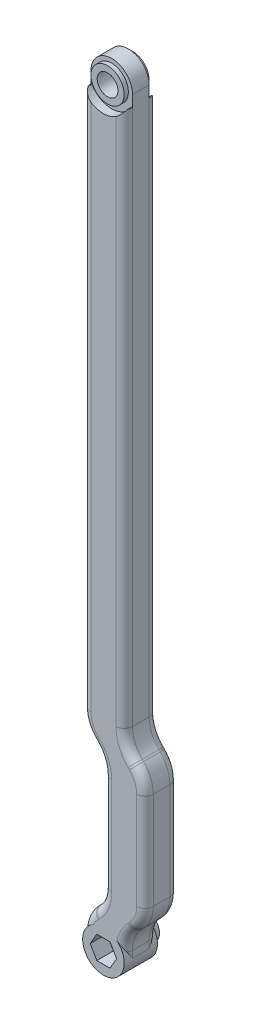
from build123d import *

# Parameters (mm, degrees)
EXTRUDE_1_DEPTH     = 8
FILLET_1_R          = 8
CUT_EXTRUDE_1_DEPTH = 1
SKETCH_3_R          = 2.5
EXTRUDE_2_DEPTH     = 4
SKETCH_4_R          = 4
CUT_EXTRUDE_3_DEPTH = 1
CUT_EXTRUDE_4_REACH = 13
SKETCH_5_R          = 2.5
CUT_EXTRUDE_START   = -7
SKETCH_4_2_R        = 4
CUT_EXTRUDE_5_DEPTH = 2
SKETCH_7_R          = 4
CUT_EXTRUDE_6_DEPTH = 1
FILLET_2_R          = 2
SKETCH_9_R          = 5
EXTRUDE_3_DEPTH     = 8
SKETCH_11_R         = 3
EXTRUDE_4_DEPTH     = 2.5
FILLET_3_R          = 1
SKETCH_12_R         = 1.6
CUT_EXTRUDE_8_DEPTH = 12
CUT_EXTRUDE_9_DEPTH = 4


with BuildPart() as part:
    # 草图1 → 凸台-拉伸1 (new body)
    with BuildSketch(Plane.XY):
        with BuildLine():
            Line((-5, -175), (-5, -180))
            ThreePointArc((-5, -180), (0, -185), (5, -180))
            Line((5, -180), (5, -175))
            Line((5, -175), (10, -170))
            Line((10, -170), (10, -140))
            Line((10, -140), (5, -135))
            Line((5, -135), (5, 0))
            ThreePointArc((5, 0), (0, 5), (-5, 0))
            Line((-5, 0), (-5, -135))
            Line((-5, -135), (0, -140))
            Line((0, -140), (0, -170))
            Line((0, -170), (-5, -175))
        make_face()
    extrude(amount=EXTRUDE_1_DEPTH)

    # 圆角1
    fillet_1_edges = [part.edges().sort_by_distance(p)[0] for p in [
        (5, -175, 4),
        (-5, -175, 4),
        (0, -170, 4),
        (0, -140, 4),
        (-5, -135, 4),
        (5, -135, 4),
        (10, -140, 4),
        (10, -170, 4),
    ]]
    fillet(fillet_1_edges, radius=FILLET_1_R)

    # 草图2 → 切除-拉伸1 (cut)
    with BuildSketch(Plane(origin=(0, 0, 0), x_dir=(-1, 0, 0), z_dir=(0, 0, -1))):
        with BuildLine():
            Line((5, 0), (5, -2.75))
            Line((5, -2.75), (4.763139721, -2.75))
            ThreePointArc((4.763139721, -2.75), (0, -5.5), (-4.763139721, -2.75))
            Line((-4.763139721, -2.75), (-5, -2.75))
            Line((-5, -2.75), (-5, 0))
            ThreePointArc((-5, 0), (0, 5), (5, 0))
        make_face()
    extrude(amount=-CUT_EXTRUDE_1_DEPTH, mode=Mode.SUBTRACT)

    # 草图3 → 凸台-拉伸2 (add)
    with BuildSketch(Plane(origin=(0, 0, 1), x_dir=(-1, 0, 0), z_dir=(0, 0, -1))):
        Circle(SKETCH_3_R)
    extrude(amount=EXTRUDE_2_DEPTH)

    # 草图4 → 切除-拉伸3 (cut)
    with BuildSketch(Plane(origin=(0, 0, 1), x_dir=(-1, 0, 0), z_dir=(0, 0, -1))):
        with BuildLine():
            Line((-5, 0), (-5, -2.75))
            Line((-5, -2.75), (-4.763139721, -2.75))
            ThreePointArc((-4.763139721, -2.75), (0, -5.5), (4.763139721, -2.75))
            Line((4.763139721, -2.75), (5, -2.75))
            Line((5, -2.75), (5, 0))
            ThreePointArc((5, 0), (0, 5), (-5, 0))
        make_face()
        Circle(SKETCH_4_R, mode=Mode.SUBTRACT)
    extrude(amount=-CUT_EXTRUDE_3_DEPTH, mode=Mode.SUBTRACT)

    # 草图5 → 切除-拉伸4 (cut, up to next)
    with BuildSketch(Plane.XY.offset(8), mode=Mode.PRIVATE) as cut_extrude_4_sk1:
        Circle(SKETCH_5_R)
    cut_extrude_4_tool1 = extrude(cut_extrude_4_sk1.sketch, amount=-CUT_EXTRUDE_4_REACH, mode=Mode.PRIVATE) & part.part
    add(cut_extrude_4_tool1.solids().sort_by_distance((0, 0, 8))[0], mode=Mode.SUBTRACT)

    # 草图4<2> → 切除-拉伸5 (cut)
    with BuildSketch(Plane(origin=(0, 0, 1), x_dir=(-1, 0, 0), z_dir=(0, 0, -1)).offset(CUT_EXTRUDE_START)):
        with BuildLine():
            Line((-5, 0), (-5, -2.75))
            Line((-5, -2.75), (-4.763139721, -2.75))
            ThreePointArc((-4.763139721, -2.75), (0, -5.5), (4.763139721, -2.75))
            Line((4.763139721, -2.75), (5, -2.75))
            Line((5, -2.75), (5, 0))
            ThreePointArc((5, 0), (0, 5), (-5, 0))
        make_face()
        Circle(SKETCH_4_2_R, mode=Mode.SUBTRACT)
    extrude(amount=CUT_EXTRUDE_5_DEPTH, mode=Mode.SUBTRACT)

    # 草图7 → 切除-拉伸6 (cut)
    with BuildSketch(Plane.XY.offset(8)):
        Circle(SKETCH_7_R)
    extrude(amount=-CUT_EXTRUDE_6_DEPTH, mode=Mode.SUBTRACT)

    # 圆角2
    fillet_2_edges = [part.edges().sort_by_distance(p)[0] for p in [
        (-4.39103626, -134.74775896, 0),
        (-2.5, -137.5, 0),
        (-0.60896374, -140.25224104, 0),
        (0, -155, 0),
        (-0.60896374, -169.74775896, 0),
        (-2.5, -172.5, 0),
        (-4.39103626, -175.25224104, 0),
        (-5, -179.156854249, 0),
        (0, -185, 0),
        (5, -179.156854249, 0),
        (5.60896374, -175.25224104, 0),
        (7.5, -172.5, 0),
        (9.39103626, -169.74775896, 0),
        (10, -155, 0),
        (9.39103626, -140.25224104, 0),
        (7.5, -137.5, 0),
        (5.60896374, -134.74775896, 0),
        (-4.39103626, -134.74775896, 8),
        (-2.5, -137.5, 8),
        (-0.60896374, -140.25224104, 8),
        (0, -155, 8),
        (-0.60896374, -169.74775896, 8),
        (-2.5, -172.5, 8),
        (-4.39103626, -175.25224104, 8),
        (-5, -179.156854249, 8),
        (0, -185, 8),
        (5, -179.156854249, 8),
        (5.60896374, -175.25224104, 8),
        (7.5, -172.5, 8),
        (9.39103626, -169.74775896, 8),
        (10, -155, 8),
        (9.39103626, -140.25224104, 8),
        (7.5, -137.5, 8),
        (5.60896374, -134.74775896, 8),
        (-5, -67.218145751, 0),
        (5, -67.218145751, 0),
        (-5, -67.218145751, 8),
        (5, -67.218145751, 8),
    ]]
    fillet(fillet_2_edges, radius=FILLET_2_R)

    # 草图9 → 凸台-拉伸3 (add)
    with BuildSketch(Plane.XY.offset(8)):
        with Locations((0, -180)):
            Circle(SKETCH_9_R)
    extrude(amount=-EXTRUDE_3_DEPTH)

    # 草图11 → 凸台-拉伸4 (add)
    with BuildSketch(Plane(origin=(0, 0, 0), x_dir=(-1, 0, 0), z_dir=(0, 0, -1))):
        with Locations((0, -180)):
            Circle(SKETCH_11_R)
    extrude(amount=EXTRUDE_4_DEPTH)

    # 圆角3
    fillet_3_edges = [part.edges().sort_by_distance(p)[0] for p in [
        (3, -180, 0),
    ]]
    fillet(fillet_3_edges, radius=FILLET_3_R)

    # 草图12 → 切除-拉伸8 (cut)
    with BuildSketch(Plane(origin=(0, 0, -2.5), x_dir=(-1, 0, 0), z_dir=(0, 0, -1))):
        with Locations((0, -180)):
            Circle(SKETCH_12_R)
    extrude(amount=-CUT_EXTRUDE_8_DEPTH, mode=Mode.SUBTRACT)

    # 草图13 → 切除-拉伸9 (cut)
    with BuildSketch(Plane.XY.offset(8)):
        Polygon((-1.58771324, -177.25), (-3.175426481, -180), (-1.58771324, -182.75), (1.58771324, -182.75), (3.175426481, -180), (1.58771324, -177.25), align=None)
    extrude(amount=-CUT_EXTRUDE_9_DEPTH, mode=Mode.SUBTRACT)


solid = part.part
